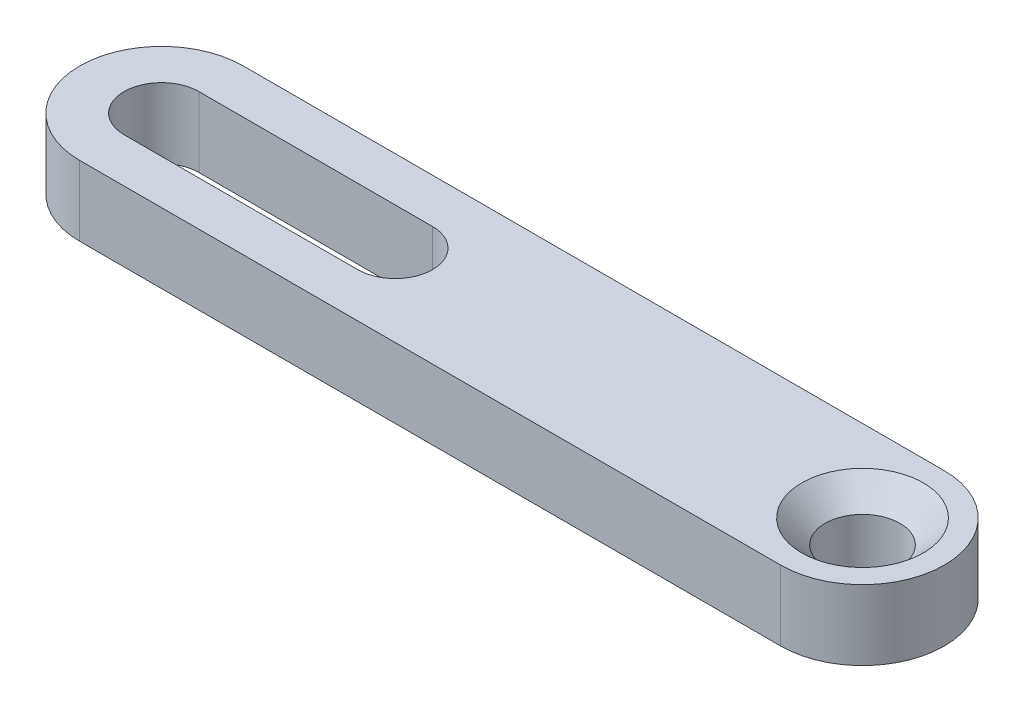
from build123d import *

# Parameters (mm, degrees)
SKETCH_1_R      = 1.6
EXTRUDE_1_DEPTH = 3
CHAMFER_1_SIZE  = 1


with BuildPart() as part:
    # Эскиз1 → Бобышка-Вытянуть1 (new body)
    with BuildSketch(Plane(origin=(0, 0, 0), x_dir=(1, 0, 0), z_dir=(0, 1, 0))):
        with BuildLine():
            Line((-30, 3.5), (0, 3.5))
            ThreePointArc((0, 3.5), (3.5, 0), (0, -3.5))
            Line((0, -3.5), (-30, -3.5))
            ThreePointArc((-30, -3.5), (-33.5, 0), (-30, 3.5))
        make_face()
        Circle(SKETCH_1_R, mode=Mode.SUBTRACT)
        with BuildLine():
            Line((-30, 1.6), (-20, 1.6))
            ThreePointArc((-20, 1.6), (-18.4, 0), (-20, -1.6))
            Line((-20, -1.6), (-30, -1.6))
            ThreePointArc((-30, -1.6), (-31.6, 0), (-30, 1.6))
        make_face(mode=Mode.SUBTRACT)
    extrude(amount=EXTRUDE_1_DEPTH)

    # Фаска1
    chamfer_1_edges = [part.edges().sort_by_distance(p)[0] for p in [
        (-1.6, 3, 0),
    ]]
    chamfer(chamfer_1_edges, length=CHAMFER_1_SIZE)


solid = part.part
